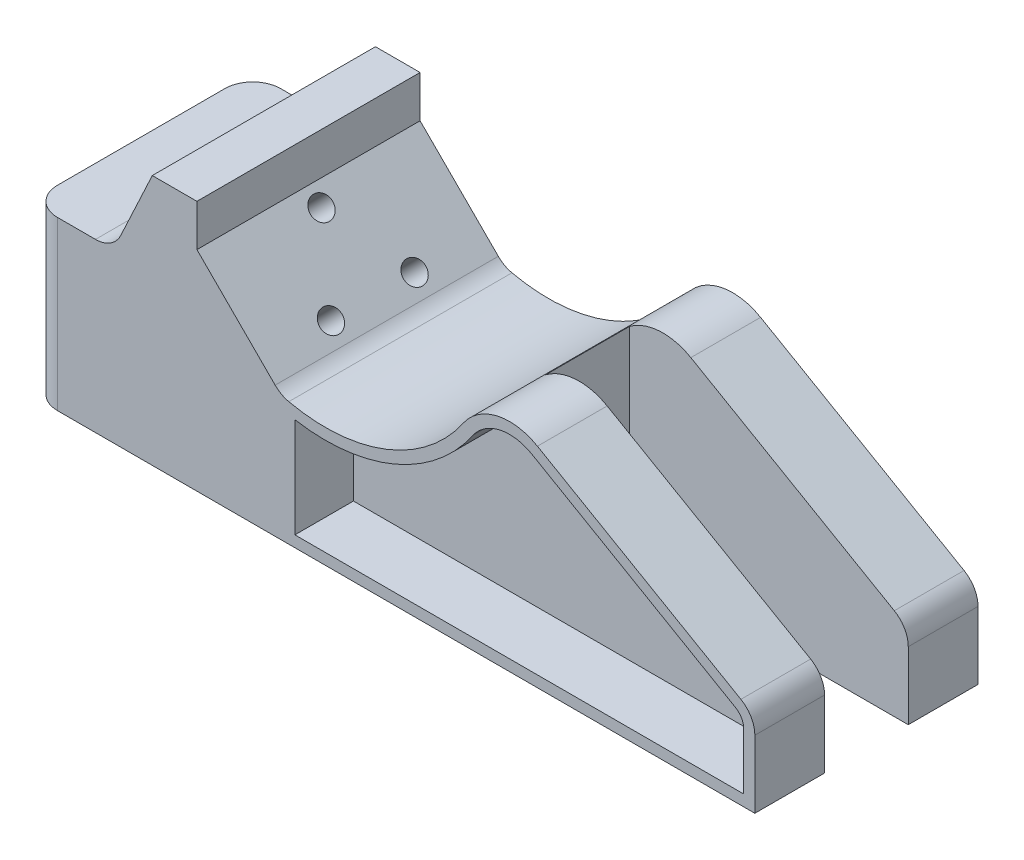
from build123d import *

# Parameters (mm, degrees)
BOSS_EXTRUDE1_DEPTH = 20
SKETCH4_W           = 63.514914878
SKETCH4_H           = 103.610922595
CUT_EXTRUDE2_DEPTH  = 7.5
CUT_EXTRUDE6_DEPTH  = 10.5
FILLET1_R           = 5
SKETCH8_R           = 2
CUT_EXTRUDE7_DEPTH  = 25
SKETCH6_R           = 2
CUT_EXTRUDE4_DEPTH  = 25


with BuildPart() as part:
    # Sketch2 → Boss-Extrude1 (new body, symmetric)
    with BuildSketch(Plane.XY):
        with BuildLine():
            Line((0, 0), (-130, 0))
            Line((-130, 0), (-130, 30))
            Line((-130, 30), (-118.185351304, 30))
            ThreePointArc((-118.185351304, 30), (-115.498853262, 30.783042771), (-113.653812369, 32.886908691))
            Line((-113.653812369, 32.886908691), (-108.005385128, 45))
            Line((-108.005385128, 45), (-100.005385128, 45))
            Line((-100.005385128, 45), (-100.005385128, 37.5))
            Line((-100.005385128, 37.5), (-85.982296413, 23.476911285))
            ThreePointArc((-85.982296413, 23.476911285), (-84.855398576, 22.63083906), (-83.537184033, 22.132795522))
            ThreePointArc((-83.537184033, 22.132795522), (-65.987052779, 23.503119369), (-52.227021097, 34.482482856))
            ThreePointArc((-52.227021097, 34.482482856), (-46.190723693, 38.590308115), (-38.97114317, 37.5))
            Line((-38.97114317, 37.5), (-2.5, 16.443375673))
            ThreePointArc((-2.5, 16.443375673), (-0.669872981, 14.613248654), (0, 12.113248654))
            Line((0, 12.113248654), (0, 0))
        make_face()
    extrude(amount=BOSS_EXTRUDE1_DEPTH, both=True)

    # Sketch4 → Cut-Extrude2 (cut, symmetric)
    with BuildSketch(Plane.XY):
        with Locations((-18.242542561, 15.758193393)):
            Rectangle(SKETCH4_W, SKETCH4_H)
    extrude(amount=CUT_EXTRUDE2_DEPTH, both=True, mode=Mode.SUBTRACT)

    # Sketch7 → Cut-Extrude6 (cut)
    with BuildSketch(Plane.XY.offset(20)):
        with BuildLine():
            Line((-82.446762507, 2), (-82.446762507, 19.878574637))
            ThreePointArc((-82.446762507, 19.878574637), (-64.532833868, 21.93692525), (-50.575845512, 33.353935477))
            ThreePointArc((-50.575845512, 33.353935477), (-45.746807589, 36.640195685), (-39.97114317, 35.767949192))
            Line((-39.97114317, 35.767949192), (-3.5, 14.711324865))
            ThreePointArc((-3.5, 14.711324865), (-2.401923789, 13.613248654), (-2, 12.113248654))
            Line((-2, 12.113248654), (-2, 2))
            Line((-2, 2), (-82.446762507, 2))
        make_face()
    extrude(amount=-CUT_EXTRUDE6_DEPTH, mode=Mode.SUBTRACT)

    # Fillet1
    fillet1_edges = [part.edges().sort_by_distance(p)[0] for p in [
        (-130, 15, -20),
        (-130, 15, 20),
    ]]
    fillet(fillet1_edges, radius=FILLET1_R)

    # Sketch8 → Cut-Extrude7 (cut)
    with BuildSketch(Plane(origin=(-31.252692564, -31.252692564, 0), x_dir=(0, 0, -1), z_dir=(0.707106781, 0.707106781, 0))):
        with Locations(Location((0, 93.930990273, 0), (0, 0, 90))):  # turned: the seam where the file's is
            Circle(SKETCH8_R)
        with Locations(Location((-7.5, 80.940609217, 0), (0, 0, 90))):  # turned: the seam where the file's is
            Circle(SKETCH8_R)
        with Locations(Location((7.5, 80.940609217, 0), (0, 0, 90))):  # turned: the seam where the file's is
            Circle(SKETCH8_R)
    extrude(amount=-CUT_EXTRUDE7_DEPTH, mode=Mode.SUBTRACT)

    # Sketch6 → Cut-Extrude4 (cut)
    with BuildSketch(Plane(origin=(-31.252692564, -31.252692564, 0), x_dir=(0, 0, -1), z_dir=(0.707106781, 0.707106781, 0))):
        with Locations(Location((0, 93.930990273, 0), (0, 0, 90))):  # turned: the seam where the file's is
            Circle(SKETCH6_R)
        with Locations(Location((-7.5, 80.940609217, 0), (0, 0, 90))):  # turned: the seam where the file's is
            Circle(SKETCH6_R)
        with Locations(Location((7.5, 80.940609217, 0), (0, 0, 90))):  # turned: the seam where the file's is
            Circle(SKETCH6_R)
    extrude(amount=-CUT_EXTRUDE4_DEPTH, mode=Mode.SUBTRACT)


solid = part.part
